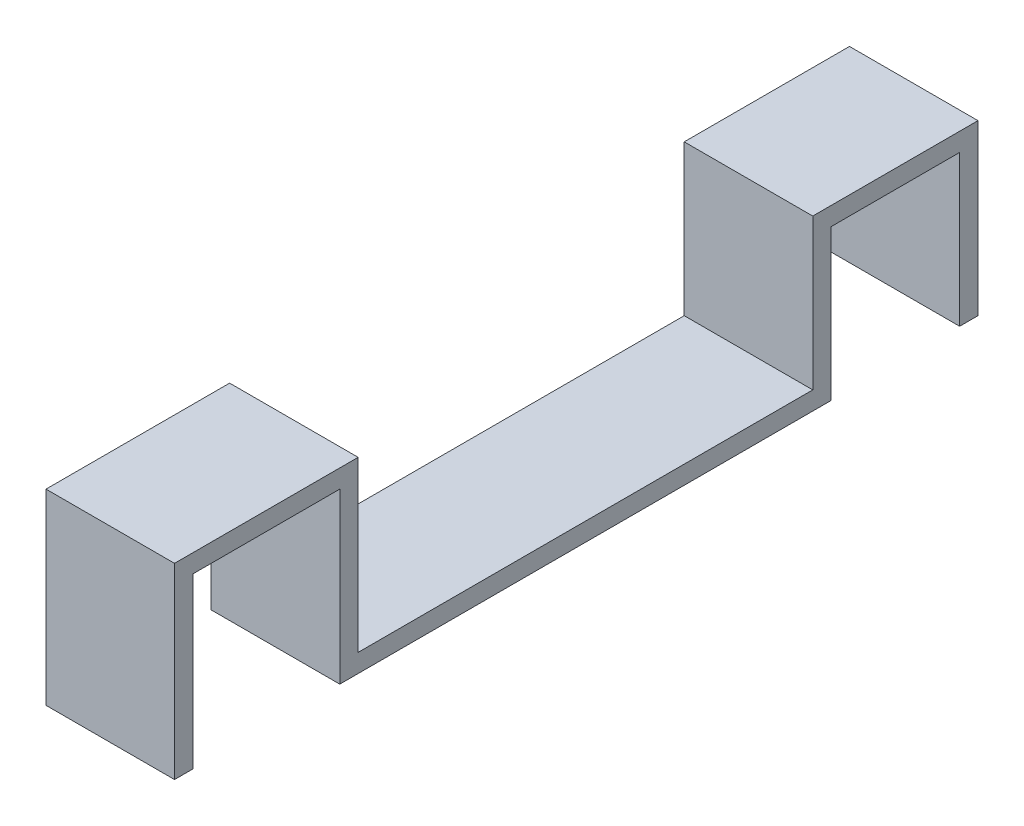
from build123d import *

# Parameters (mm, degrees)
SKETCH_1_W       = 35
SKETCH_1_H       = 123.8
EXTRUDE_1_DEPTH  = 5
SKETCH_2_W       = 35
SKETCH_2_H       = 41
EXTRUDE_3_DEPTH  = 5
SKETCH_3_W       = 35
SKETCH_3_H       = 5
EXTRUDE_4_DEPTH  = 5
SKETCH_4_W       = 35
SKETCH_4_H       = 5
EXTRUDE_5_DEPTH  = 40
SKETCH_5_W       = 35
SKETCH_5_H       = 5
EXTRUDE_6_DEPTH  = 41
SKETCH_8_W       = 35
SKETCH_8_H       = 5
EXTRUDE_7_DEPTH  = 5
SKETCH_12_W      = 35
SKETCH_12_H      = 5
EXTRUDE_8_DEPTH  = 46
SKETCH_13_W      = 35
SKETCH_13_H      = 5
EXTRUDE_9_DEPTH  = 45
SKETCH_14_W      = 35
SKETCH_14_H      = 5
EXTRUDE_10_DEPTH = 46


with BuildPart() as part:
    # 草圖1 → 填料-伸長1 (new body)
    with BuildSketch(Plane(origin=(0, 0, 0), x_dir=(1, 0, 0), z_dir=(0, 1, 0))):
        Rectangle(SKETCH_1_W, SKETCH_1_H)
    extrude(amount=EXTRUDE_1_DEPTH)



with BuildPart() as body_2:
    # 草圖2 → 填料-伸長3 (new body)
    with BuildSketch(Plane(origin=(0, 0, -61.9), x_dir=(-1, 0, 0), z_dir=(0, 0, -1))):
        with Locations((0, 25.5)):
            Rectangle(SKETCH_2_W, SKETCH_2_H)
    extrude(amount=EXTRUDE_3_DEPTH)


with BuildPart() as part_1:
    add(part.part)

    add(body_2.part)  # 填料-伸長4 merges body 2
    # 草圖3 → 填料-伸長4 (add)
    with BuildSketch(Plane(origin=(0, 0, -61.9), x_dir=(-1, 0, 0), z_dir=(0, 0, -1))):
        with Locations((0, 2.5)):
            Rectangle(SKETCH_3_W, SKETCH_3_H)
    extrude(amount=EXTRUDE_4_DEPTH)

    # 草圖4 → 填料-伸長5 (add)
    with BuildSketch(Plane(origin=(0, 0, -66.9), x_dir=(-1, 0, 0), z_dir=(0, 0, -1))):
        with Locations((0, 43.5)):
            Rectangle(SKETCH_4_W, SKETCH_4_H)
    extrude(amount=EXTRUDE_5_DEPTH)

    # 草圖5 → 填料-伸長6 (add)
    with BuildSketch(Plane.XZ.offset(-41)):
        with Locations((0, -104.4)):
            Rectangle(SKETCH_5_W, SKETCH_5_H)
    extrude(amount=EXTRUDE_6_DEPTH)

    # 草圖8 → 填料-伸長7 (add)
    with BuildSketch(Plane.XY.offset(61.9)):
        with Locations((0, 2.5)):
            Rectangle(SKETCH_8_W, SKETCH_8_H)
    extrude(amount=EXTRUDE_7_DEPTH)

    # 草圖12 → 填料-伸長8 (add)
    with BuildSketch(Plane(origin=(0, 5, 0), x_dir=(1, 0, 0), z_dir=(0, 1, 0))):
        with Locations((0, -64.4)):
            Rectangle(SKETCH_12_W, SKETCH_12_H)
    extrude(amount=EXTRUDE_8_DEPTH)

    # 草圖13 → 填料-伸長9 (add)
    with BuildSketch(Plane.XY.offset(66.9)):
        with Locations((0, 48.5)):
            Rectangle(SKETCH_13_W, SKETCH_13_H)
    extrude(amount=EXTRUDE_9_DEPTH)

    # 草圖14 → 填料-伸長10 (add)
    with BuildSketch(Plane.XZ.offset(-46)):
        with Locations((0, 109.4)):
            Rectangle(SKETCH_14_W, SKETCH_14_H)
    extrude(amount=EXTRUDE_10_DEPTH)


solid = part_1.part
